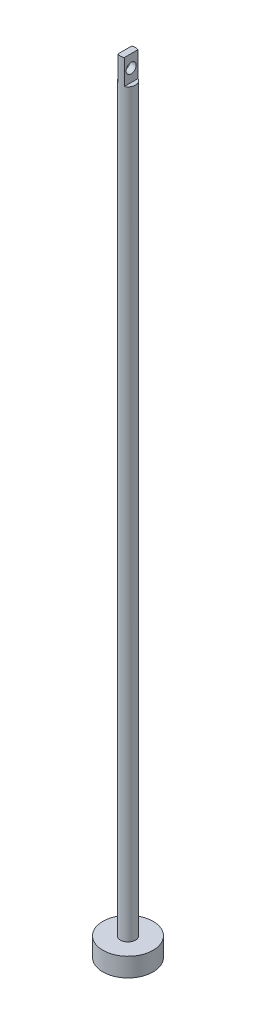
from build123d import *

# Parameters (mm, degrees)
SKETCH_1_R           = 20
EXTRUDE_1_DEPTH      = 15
SKETCH_2_R           = 6
EXTRUDE_2_DEPTH      = 610
SKETCH_3_OUTSIDE_W   = 167.51
SKETCH_3_OUTSIDE_H   = 167.51
SKETCH_3_OUTSIDE_W_2 = 5
SKETCH_3_OUTSIDE_H_2 = 20
CUT_EXTRUDE_1_DEPTH  = 20
SKETCH_4_R           = 4
CUT_EXTRUDE_2_DEPTH  = 20


with BuildPart() as part:
    # 草图1 → 凸台-拉伸1 (new body)
    with BuildSketch(Plane(origin=(0, 0, 0), x_dir=(1, 0, 0), z_dir=(0, 1, 0))):
        Circle(SKETCH_1_R)
    extrude(amount=EXTRUDE_1_DEPTH)

    # 草图2 → 凸台-拉伸2 (add)
    with BuildSketch(Plane(origin=(0, 15, 0), x_dir=(1, 0, 0), z_dir=(0, 1, 0))):
        Circle(SKETCH_2_R)
    extrude(amount=EXTRUDE_2_DEPTH)

    # 草图3 outside → 切除-拉伸1 (cut)
    with BuildSketch(Plane(origin=(0, 625, 0), x_dir=(1, 0, 0), z_dir=(0, 1, 0))):
        Rectangle(SKETCH_3_OUTSIDE_W, SKETCH_3_OUTSIDE_H)
        Rectangle(SKETCH_3_OUTSIDE_W_2, SKETCH_3_OUTSIDE_H_2, mode=Mode.SUBTRACT)
    extrude(amount=-CUT_EXTRUDE_1_DEPTH, mode=Mode.SUBTRACT)

    # 草图4 → 切除-拉伸2 (cut)
    with BuildSketch(Plane.ZY.offset(2.5)):
        with Locations((0, 615)):
            Circle(SKETCH_4_R)
    extrude(amount=-CUT_EXTRUDE_2_DEPTH, mode=Mode.SUBTRACT)


solid = part.part
